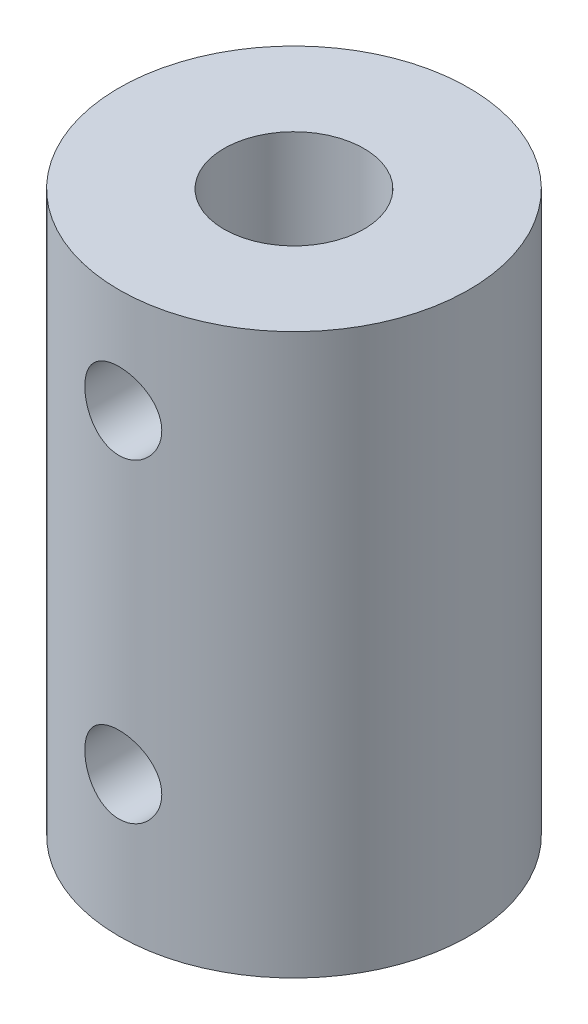
from build123d import *

# Parameters (mm, degrees)
SKETCH1_R              = 7.5
BOSS_EXTRUDE1_DEPTH    = 24
SKETCH6_R              = 3
CUT_EXTRUDE3_DEPTH     = 8
SKETCH3_R              = 4
CUT_EXTRUDE2_DEPTH     = 12
M4_TAPPED_HOLE1_REACH  = 17
M4_TAPPED_HOLE1_BORE_R = 1.65


with BuildPart() as part:
    # Sketch1 → Boss-Extrude1 (new body)
    with BuildSketch(Plane(origin=(0, 0, 0), x_dir=(1, 0, 0), z_dir=(0, 1, 0))):
        with Locations(Location((0, 0, 0), (0, 0, 270))):  # turned: the seam where the file's is
            Circle(SKETCH1_R)
    extrude(amount=-BOSS_EXTRUDE1_DEPTH)

    # Sketch6 → Cut-Extrude3 (cut)
    with BuildSketch(Plane(origin=(0, 0, 0), x_dir=(1, 0, 0), z_dir=(0, 1, 0))):
        with Locations(Location((0, 0, 0), (0, 0, 270))):  # turned: the seam where the file's is
            Circle(SKETCH6_R)
    extrude(amount=-CUT_EXTRUDE3_DEPTH, mode=Mode.SUBTRACT)

    # Sketch3 → Cut-Extrude2 (cut)
    with BuildSketch(Plane.XZ.offset(24)):
        with Locations(Location((0, 0, 0), (0, 0, 270))):  # turned: the seam where the file's is
            Circle(SKETCH3_R)
    extrude(amount=-CUT_EXTRUDE2_DEPTH, mode=Mode.SUBTRACT)

    # M4 Tapped Hole1 bore (on position points) → M4 Tapped Hole1 (cut, up to next)
    with BuildSketch(Plane(origin=(0, -4.5, 7.5), x_dir=(1, 0, 0), z_dir=(0, 0, 1)), mode=Mode.PRIVATE) as m4_tapped_hole1_sk1:
        Circle(M4_TAPPED_HOLE1_BORE_R)
    m4_tapped_hole1_tool1 = extrude(m4_tapped_hole1_sk1.sketch, amount=-M4_TAPPED_HOLE1_REACH, mode=Mode.PRIVATE) & part.part
    add(m4_tapped_hole1_tool1.solids().sort_by_distance((0, -4.5, 7.5))[0], mode=Mode.SUBTRACT)
    # M4 Tapped Hole1 bore (on position points) → M4 Tapped Hole1 (cut, up to next)
    with BuildSketch(Plane(origin=(0, -4.5, 7.5), x_dir=(1, 0, 0), z_dir=(0, 0, 1)), mode=Mode.PRIVATE) as m4_tapped_hole1_sk2:
        with Locations((0, -13.5)):
            Circle(M4_TAPPED_HOLE1_BORE_R)
    m4_tapped_hole1_tool2 = extrude(m4_tapped_hole1_sk2.sketch, amount=-M4_TAPPED_HOLE1_REACH, mode=Mode.PRIVATE) & part.part
    add(m4_tapped_hole1_tool2.solids().sort_by_distance((0, -18, 7.5))[0], mode=Mode.SUBTRACT)


solid = part.part
